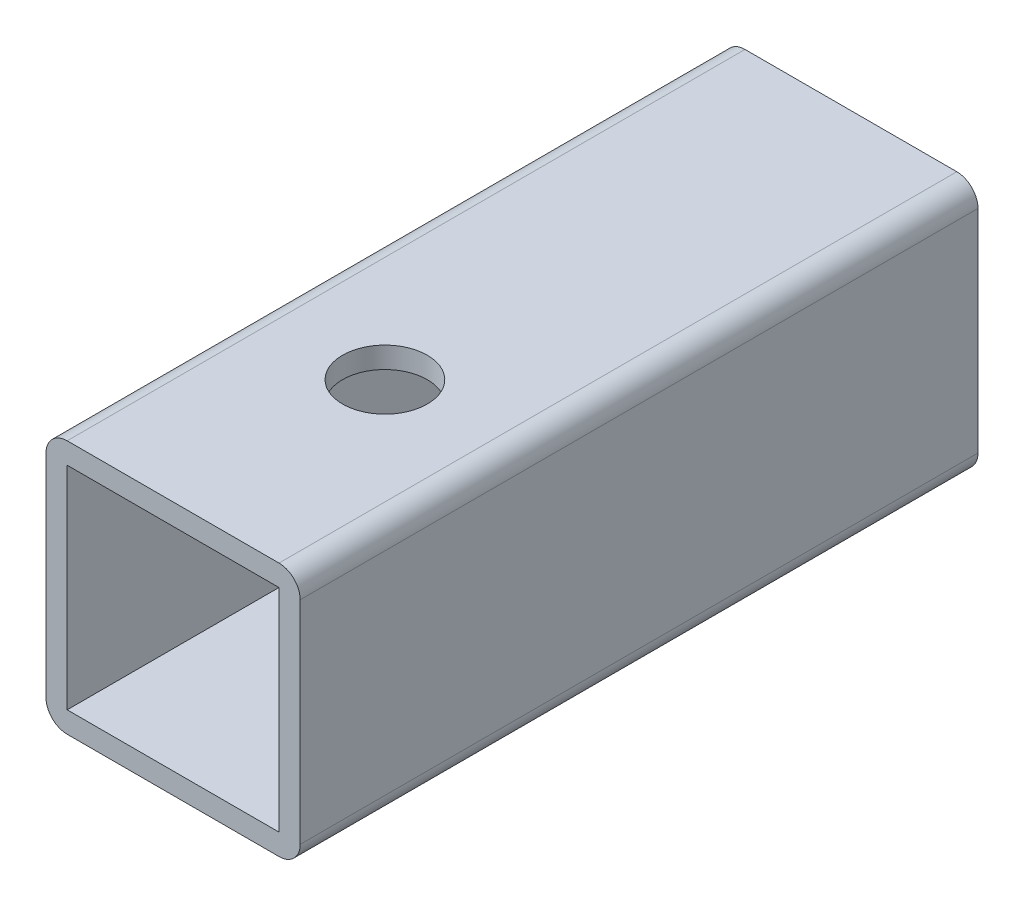
from build123d import *

# Parameters (mm, degrees)
SKETCH1_W                  = 38.1
SKETCH1_H                  = 38.1
SKETCH1_W_2                = 31.75
SKETCH1_H_2                = 31.75
EXTRUDE1_DEPTH             = 101.6
FILLET1_R                  = 3.175
F_1_2_0_5_DIAMETER_HOLE1_D = 12.7


with BuildPart() as part:
    # Sketch1 → Extrude1 (new body)
    with BuildSketch(Plane.XY):
        Rectangle(SKETCH1_W, SKETCH1_H)
        Rectangle(SKETCH1_W_2, SKETCH1_H_2, mode=Mode.SUBTRACT)
    extrude(amount=EXTRUDE1_DEPTH)

    # Fillet1
    fillet1_edges = [part.edges().sort_by_distance(p)[0] for p in [
        (19.05, -19.05, 50.8),
        (-19.05, -19.05, 50.8),
        (-19.05, 19.05, 50.8),
        (19.05, 19.05, 50.8),
    ]]
    fillet(fillet1_edges, radius=FILLET1_R)

    # 1/2 (0.5) Diameter Hole1 (through all)
    with Locations(Plane.XZ.offset(19.05)):
        with Locations((0, 69.85)):
            Hole(F_1_2_0_5_DIAMETER_HOLE1_D / 2)


solid = part.part
